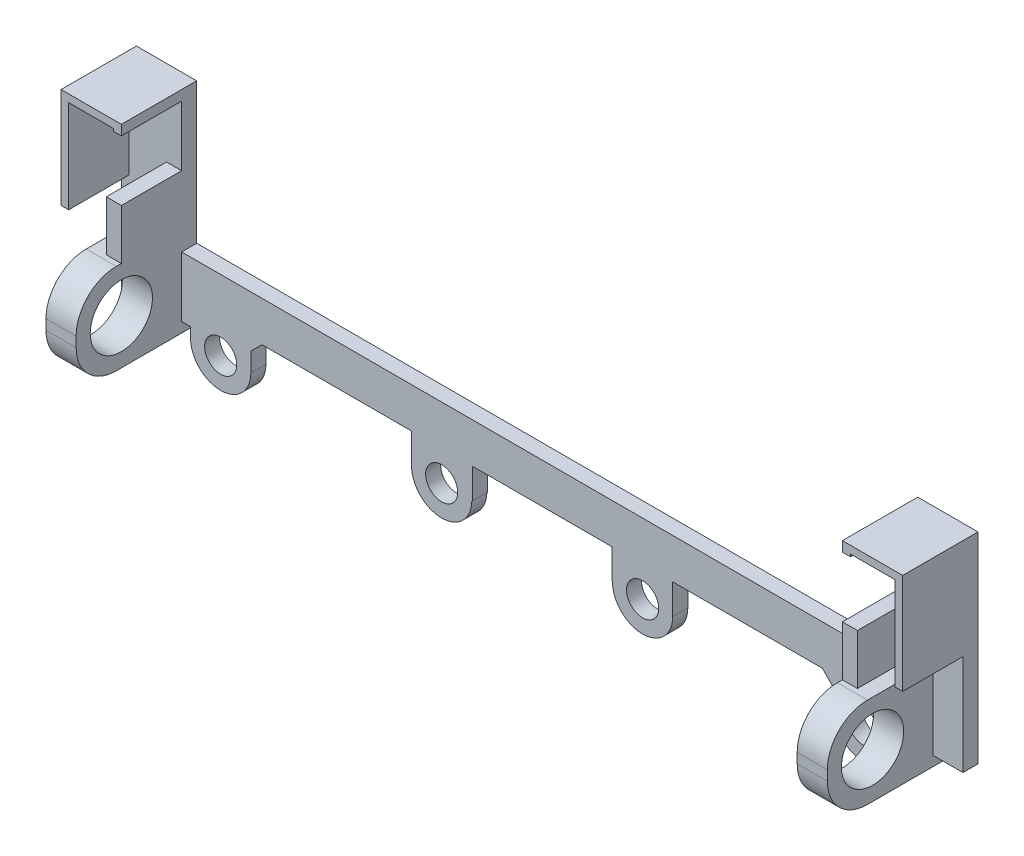
from build123d import *

# Parameters (mm, degrees)
SKETCH1_R            = 1.6
BOSS_EXTRUDE1_DEPTH  = 1.5
SKETCH2_W            = 1
SKETCH2_H            = 18
BOSS_EXTRUDE2_DEPTH  = 1.5
BOSS_EXTRUDE3_DEPTH  = 6
BOSS_EXTRUDE4_DEPTH  = 6
SKETCH5_W            = 1.5
SKETCH5_H            = 7
BOSS_EXTRUDE5_DEPTH  = 6
BOSS_EXTRUDE6_DEPTH  = 1.5
SKETCH7_W            = 3
SKETCH7_H            = 6
BOSS_EXTRUDE7_DEPTH  = 12
SKETCH8_W            = 3
SKETCH8_H            = 9
BOSS_EXTRUDE8_DEPTH  = 13.5
SKETCH10_W           = 3
SKETCH10_H           = 2
CUT_EXTRUDE2_DEPTH   = 141
SKETCH11_W           = 3
SKETCH11_H           = 2
BOSS_EXTRUDE9_DEPTH  = 12
SKETCH12_R           = 3.1
SKETCH12_W           = 1.5
SKETCH12_H           = 9
CUT_EXTRUDE6_DEPTH   = 86
FILLET4_R            = 4
SKETCH13_R           = 1.6
BOSS_EXTRUDE10_DEPTH = 1.5
SKETCH14_R           = 1.6
CUT_EXTRUDE7_DEPTH   = 1.5


with BuildPart() as part:
    # Sketch1 → Boss-Extrude1 (new body)
    with BuildSketch(Plane.XY):
        with BuildLine():
            Line((-35.88879481, 0), (35.88879481, 0))
            Line((35.88879481, 0), (35.88879481, 14))
            Line((35.88879481, 14), (40.88879481, 14))
            Line((40.88879481, 14), (40.88879481, -4))
            Line((40.88879481, -4), (35.88879481, -4))
            Line((35.88879481, -4), (13, -4))
            Line((13, -4), (13, -7))
            ThreePointArc((13, -7), (10, -10), (7, -7))
            Line((7, -7), (6.947208763, -7))
            Line((6.947208763, -7), (6.947208763, -4))
            Line((6.947208763, -4), (-6.947208763, -4))
            Line((-6.947208763, -4), (-6.947208763, -7))
            Line((-6.947208763, -7), (-7, -7))
            ThreePointArc((-7, -7), (-10, -10), (-13, -7))
            Line((-13, -7), (-13, -4))
            Line((-13, -4), (-35.88879481, -4))
            Line((-35.88879481, -4), (-40.88879481, -4))
            Line((-40.88879481, -4), (-40.88879481, 14))
            Line((-40.88879481, 14), (-35.88879481, 14))
            Line((-35.88879481, 14), (-35.88879481, 0))
        make_face()
        with Locations((10, -7)):
            Circle(SKETCH1_R, mode=Mode.SUBTRACT)
        with Locations((-10, -7)):
            Circle(SKETCH1_R, mode=Mode.SUBTRACT)
    extrude(amount=BOSS_EXTRUDE1_DEPTH)

    # Sketch2 → Boss-Extrude2 (add)
    with BuildSketch(Plane.XY.offset(1.5)):
        with Locations((41.38879481, 5)):
            Rectangle(SKETCH2_W, SKETCH2_H)
        with Locations((-41.38879481, 5)):
            Rectangle(SKETCH2_W, SKETCH2_H)
    extrude(amount=-BOSS_EXTRUDE2_DEPTH)

    # Sketch3 → Boss-Extrude3 (add)
    with BuildSketch(Plane.XY.offset(1.5)):
        Polygon((35.88879481, 14), (41.88879481, 14), (41.88879481, 4), (41.38879481, 4), (41.38879481, 13.5), (36.68879481, 13.5), (36.68879481, 13), (35.88879481, 13), align=None)
        Polygon((-36.68879481, 13.5), (-41.38879481, 13.5), (-41.38879481, 4), (-41.88879481, 4), (-41.88879481, 14), (-35.88879481, 14), (-35.88879481, 13), (-36.68879481, 13), align=None)
    extrude(amount=BOSS_EXTRUDE3_DEPTH)

    # Sketch4 → Boss-Extrude4 (add)
    with BuildSketch(Plane.XY.offset(7.5)):
        Polygon((-41.38879481, 4), (-41.13879481, 4), (-41.13879481, 13.12888012), (-41.13879481, 13.25), (-36.68879481, 13.25), (-36.68879481, 13.5), (-41.38879481, 13.5), align=None)
        Polygon((41.38879481, 13.5), (41.38879481, 4), (41.13879481, 4), (41.13879481, 13.12888012), (41.13879481, 13.25), (36.68879481, 13.25), (36.68879481, 13.5), align=None)
    extrude(amount=-BOSS_EXTRUDE4_DEPTH)

    # Sketch5 → Boss-Extrude5 (add)
    with BuildSketch(Plane.XY.offset(1.5)):
        with Locations((-36.63879481, 3.5)):
            Rectangle(SKETCH5_W, SKETCH5_H)
        with Locations((36.63879481, 3.5)):
            Rectangle(SKETCH5_W, SKETCH5_H)
    extrude(amount=BOSS_EXTRUDE5_DEPTH)

    # Sketch6 → Boss-Extrude6 (add)
    with BuildSketch(Plane.XY.offset(1.5)):
        Polygon((41.88879481, -4), (41.88879481, -6), (29.88879481, -6), (27.88879481, -4), align=None)
        Polygon((-27.88879481, -4), (-41.88879481, -4), (-41.88879481, -6), (-29.88879481, -6), align=None)
    extrude(amount=-BOSS_EXTRUDE6_DEPTH)

    # Sketch7 → Boss-Extrude7 (add)
    with BuildSketch(Plane.XY.offset(1.5)):
        with Locations((37.38879481, -3)):
            Rectangle(SKETCH7_W, SKETCH7_H)
        with Locations((-37.38879481, -3)):
            Rectangle(SKETCH7_W, SKETCH7_H)
    extrude(amount=BOSS_EXTRUDE7_DEPTH)

    # Sketch8 → Boss-Extrude8 (add)
    with BuildSketch(Plane.XY.offset(13.5)):
        with Locations((-37.38879481, -4.5)):
            Rectangle(SKETCH8_W, SKETCH8_H)
        with Locations((37.38879481, -4.5)):
            Rectangle(SKETCH8_W, SKETCH8_H)
    extrude(amount=-BOSS_EXTRUDE8_DEPTH)

    # Sketch10 → Cut-Extrude2 (cut)
    with BuildSketch(Plane.XY.offset(13.5)):
        with Locations((-37.38879481, -8)):
            Rectangle(SKETCH10_W, SKETCH10_H)
        with Locations((37.38879481, -8)):
            Rectangle(SKETCH10_W, SKETCH10_H)
    extrude(amount=-CUT_EXTRUDE2_DEPTH, mode=Mode.SUBTRACT)

    # Sketch11 → Boss-Extrude9 (add)
    with BuildSketch(Plane.XY.offset(13.5)):
        with Locations((-37.38879481, 1)):
            Rectangle(SKETCH11_W, SKETCH11_H)
        with Locations((37.38879481, 1)):
            Rectangle(SKETCH11_W, SKETCH11_H)
    extrude(amount=-BOSS_EXTRUDE9_DEPTH)

    # Sketch12 → Cut-Extrude6 (cut)
    with BuildSketch(Plane(origin=(38.88879481, 0, 0), x_dir=(0, 0, -1), z_dir=(1, 0, 0))):
        with Locations((-7.5, -2.5)):
            Circle(SKETCH12_R)
        with Locations((-12.75, -2.5)):
            Rectangle(SKETCH12_W, SKETCH12_H)
    extrude(amount=-CUT_EXTRUDE6_DEPTH, mode=Mode.SUBTRACT)

    # Fillet4
    fillet4_edges = [part.edges().sort_by_distance(p)[0] for p in [
        (37.38879481, 2, 12),
        (37.38879481, -7, 12),
        (-37.38879481, -7, 12),
        (-37.38879481, 2, 12),
    ]]
    fillet(fillet4_edges, radius=FILLET4_R)

    # Sketch13 → Boss-Extrude10 (add)
    with BuildSketch(Plane.XY.offset(1.5)):
        with BuildLine():
            Line((-29, -7), (-29, -2.59629788))
            Line((-29, -2.59629788), (-35, -2.59629788))
            Line((-35, -2.59629788), (-35, -7))
            ThreePointArc((-35, -7), (-32, -10), (-29, -7))
        make_face()
        with Locations((-32, -7)):
            Circle(SKETCH13_R, mode=Mode.SUBTRACT)
        with BuildLine():
            Line((35, -2.59629788), (29, -2.59629788))
            Line((29, -2.59629788), (29, -7))
            ThreePointArc((29, -7), (32, -10), (35, -7))
            Line((35, -7), (35, -2.59629788))
        make_face()
        with Locations((32, -7)):
            Circle(SKETCH13_R, mode=Mode.SUBTRACT)
    extrude(amount=-BOSS_EXTRUDE10_DEPTH)

    # Sketch14 → Cut-Extrude7 (cut)
    with BuildSketch(Plane.XY.offset(1.5)):
        with Locations((-32, -7)):
            Circle(SKETCH14_R)
        with Locations((32, -7)):
            Circle(SKETCH14_R)
    extrude(amount=-CUT_EXTRUDE7_DEPTH, mode=Mode.SUBTRACT)


solid = part.part
